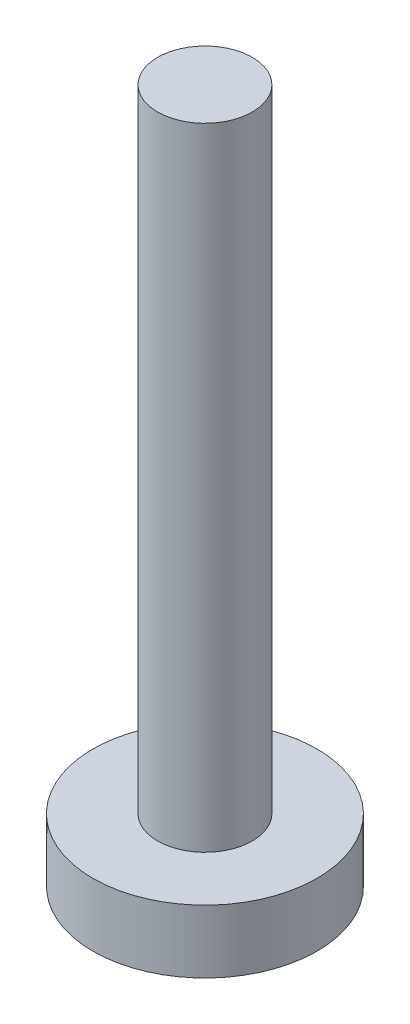
from build123d import *

# Parameters (mm, degrees)
SKETCH_1_R      = 3.55
EXTRUDE_1_DEPTH = 2
SKETCH_2_R      = 1.5
EXTRUDE_2_DEPTH = 20


with BuildPart() as part:
    # 草图1 → 凸台-拉伸1 (new body)
    with BuildSketch(Plane(origin=(0, 0, 0), x_dir=(1, 0, 0), z_dir=(0, 1, 0))):
        Circle(SKETCH_1_R)
    extrude(amount=EXTRUDE_1_DEPTH)

    # 草图2 → 凸台-拉伸2 (add)
    with BuildSketch(Plane(origin=(0, 2, 0), x_dir=(1, 0, 0), z_dir=(0, 1, 0))):
        Circle(SKETCH_2_R)
    extrude(amount=EXTRUDE_2_DEPTH)


solid = part.part
